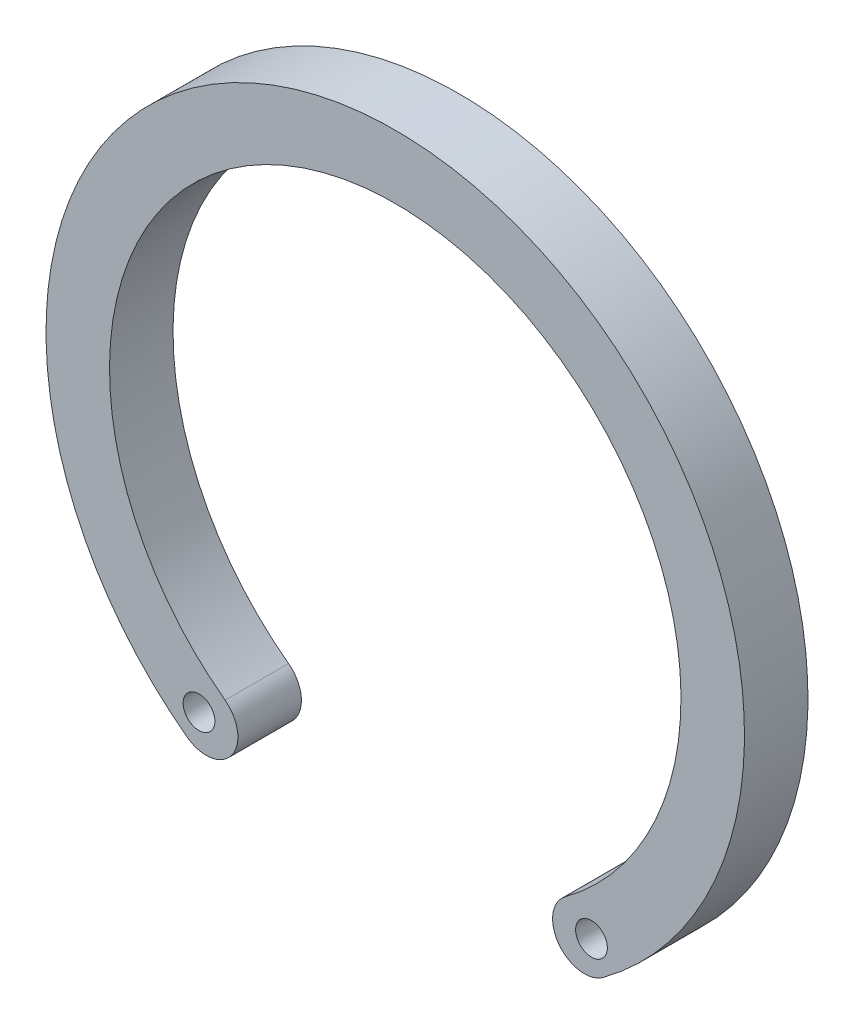
from build123d import *

# Parameters (mm, degrees)
BOSS_EXTRUDE1_DEPTH = 1
SKETCH2_R           = 0.25
CUT_EXTRUDE1_DEPTH  = 1


with BuildPart() as part:
    # Sketch1 → Boss-Extrude1 (new body)
    with BuildSketch(Plane.XY):
        with BuildLine():
            ThreePointArc((2.680014273, -3.614902972), (0, 4.5), (-2.680014273, -3.614902972))
            ThreePointArc((-2.680014273, -3.614902972), (-2.57613775, -4.314338222), (-3.275573, -4.418214744))
            ThreePointArc((-3.275573, -4.418214744), (0, 5.5), (3.275573, -4.418214744))
            ThreePointArc((3.275573, -4.418214744), (2.57613775, -4.314338222), (2.680014273, -3.614902972))
        make_face()
    extrude(amount=BOSS_EXTRUDE1_DEPTH)

    # Sketch2 → Cut-Extrude1 (cut)
    with BuildSketch(Plane.XY.offset(1)):
        with Locations((-3.090538889, -3.984232302)):
            Circle(SKETCH2_R)
        with Locations((3.090538889, -3.984232302)):
            Circle(SKETCH2_R)
    extrude(amount=-CUT_EXTRUDE1_DEPTH, mode=Mode.SUBTRACT)


solid = part.part
